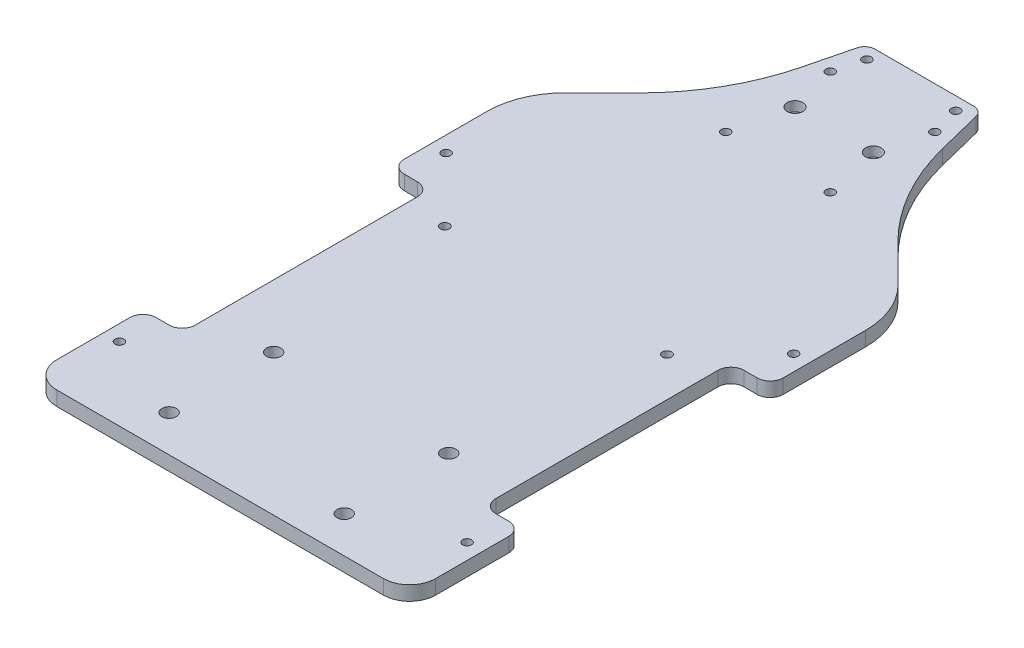
from build123d import *

# Parameters (mm, degrees)
DECK_BASE_DEPTH     = 5.5
BOLT_SLOT_REACH     = 7.5
SKETCH_3_R          = 1.7
FILLET_1_R          = 4
CUT_EXTRUDE_2_REACH = 7.5
SKETCH_11_W         = 15
SKETCH_11_H         = 95
CUT_EXTRUDE_1_REACH = 7.5
SKETCH_10_W         = 145
SKETCH_10_H         = 38.5
FILLET_2_R          = 10
FILLET_3_R          = 5
LIDAR_SLOT_REACH    = 7.5
SKETCH_4_R          = 1.7
VESC_SLOT_REACH     = 7.5
SKETCH_6_R          = 2.75
NANO_SLOT_REACH     = 7.5
SKETCH_7_R          = 1.75
CUT_EXTRUDE_3_REACH = 7.5
SKETCH_12_R         = 1.75
SKETCH_13_R         = 3
CUT_EXTRUDE_4_DEPTH = 3.7


with BuildPart() as part:
    # 스케치1 → Deck base (new body)
    with BuildSketch(Plane(origin=(0, 0, 0), x_dir=(1, 0, 0), z_dir=(0, 1, 0))):
        with BuildLine():
            Line((-72.5, 0), (-72.5, -180))
            ThreePointArc((-72.5, -180), (-69.571067812, -187.071067812), (-62.5, -190))
            Line((-62.5, -190), (-49.196112248, -190))
            ThreePointArc((-49.196112248, -190), (-47.589899161, -190.265015363), (-46.15395453, -191.031968194))
            Line((-46.15395453, -191.031968194), (-18.84604547, -211.968031806))
            ThreePointArc((-18.84604547, -211.968031806), (-17.410100839, -212.734984637), (-15.803887752, -213))
            Line((-15.803887752, -213), (15.803887752, -213))
            ThreePointArc((15.803887752, -213), (17.410100839, -212.734984637), (18.84604547, -211.968031806))
            Line((18.84604547, -211.968031806), (46.15395453, -191.031968194))
            ThreePointArc((46.15395453, -191.031968194), (47.589899161, -190.265015363), (49.196112248, -190))
            Line((49.196112248, -190), (62.5, -190))
            ThreePointArc((62.5, -190), (69.571067812, -187.071067812), (72.5, -180))
            Line((72.5, -180), (72.5, 0))
            ThreePointArc((72.5, 0), (70.204904333, 11.508182998), (63.670781605, 21.255540601))
            Line((63.670781605, 21.255540601), (49.478231298, 35.391496426))
            ThreePointArc((49.478231298, 35.391496426), (35.536990456, 53.662264501), (27, 75))
            Line((27, 75), (22, 95))
            Line((22, 95), (-22, 95))
            Line((-22, 95), (-27, 75))
            ThreePointArc((-27, 75), (-35.536990456, 53.662264501), (-49.478231298, 35.391496426))
            Line((-49.478231298, 35.391496426), (-63.670781605, 21.255540601))
            ThreePointArc((-63.670781605, 21.255540601), (-70.204904333, 11.508182998), (-72.5, 0))
        make_face()
    extrude(amount=DECK_BASE_DEPTH)

    # 스케치3 → Bolt slot (cut, up to next)
    with BuildSketch(Plane(origin=(0, 5.5, 0), x_dir=(1, 0, 0), z_dir=(0, 1, 0)), mode=Mode.PRIVATE) as bolt_slot_sk1:
        with Locations((17, 90)):
            Circle(SKETCH_3_R)
    bolt_slot_tool1 = extrude(bolt_slot_sk1.sketch, amount=-BOLT_SLOT_REACH, mode=Mode.PRIVATE) & part.part
    add(bolt_slot_tool1.solids().sort_by_distance((17, 5.5, -90))[0], mode=Mode.SUBTRACT)
    # 스케치3 → Bolt slot (cut, up to next)
    with BuildSketch(Plane(origin=(0, 5.5, 0), x_dir=(1, 0, 0), z_dir=(0, 1, 0)), mode=Mode.PRIVATE) as bolt_slot_sk2:
        with Locations((66.5, -146.5)):
            Circle(SKETCH_3_R)
    bolt_slot_tool2 = extrude(bolt_slot_sk2.sketch, amount=-BOLT_SLOT_REACH, mode=Mode.PRIVATE) & part.part
    add(bolt_slot_tool2.solids().sort_by_distance((66.5, 5.5, 146.5))[0], mode=Mode.SUBTRACT)
    # 스케치3 → Bolt slot (cut, up to next)
    with BuildSketch(Plane(origin=(0, 5.5, 0), x_dir=(1, 0, 0), z_dir=(0, 1, 0)), mode=Mode.PRIVATE) as bolt_slot_sk3:
        with Locations((66.5, -116.5)):
            Circle(SKETCH_3_R)
    bolt_slot_tool3 = extrude(bolt_slot_sk3.sketch, amount=-BOLT_SLOT_REACH, mode=Mode.PRIVATE) & part.part
    add(bolt_slot_tool3.solids().sort_by_distance((66.5, 5.5, 116.5))[0], mode=Mode.SUBTRACT)
    # 스케치3 → Bolt slot (cut, up to next)
    with BuildSketch(Plane(origin=(0, 5.5, 0), x_dir=(1, 0, 0), z_dir=(0, 1, 0)), mode=Mode.PRIVATE) as bolt_slot_sk4:
        with Locations((66.5, -51.5)):
            Circle(SKETCH_3_R)
    bolt_slot_tool4 = extrude(bolt_slot_sk4.sketch, amount=-BOLT_SLOT_REACH, mode=Mode.PRIVATE) & part.part
    add(bolt_slot_tool4.solids().sort_by_distance((66.5, 5.5, 51.5))[0], mode=Mode.SUBTRACT)
    # 스케치3 → Bolt slot (cut, up to next)
    with BuildSketch(Plane(origin=(0, 5.5, 0), x_dir=(1, 0, 0), z_dir=(0, 1, 0)), mode=Mode.PRIVATE) as bolt_slot_sk5:
        with Locations((66.5, -21.5)):
            Circle(SKETCH_3_R)
    bolt_slot_tool5 = extrude(bolt_slot_sk5.sketch, amount=-BOLT_SLOT_REACH, mode=Mode.PRIVATE) & part.part
    add(bolt_slot_tool5.solids().sort_by_distance((66.5, 5.5, 21.5))[0], mode=Mode.SUBTRACT)
    # 스케치3 → Bolt slot (cut, up to next)
    with BuildSketch(Plane(origin=(0, 5.5, 0), x_dir=(1, 0, 0), z_dir=(0, 1, 0)), mode=Mode.PRIVATE) as bolt_slot_sk6:
        with Locations((-66.5, -21.5)):
            Circle(SKETCH_3_R)
    bolt_slot_tool6 = extrude(bolt_slot_sk6.sketch, amount=-BOLT_SLOT_REACH, mode=Mode.PRIVATE) & part.part
    add(bolt_slot_tool6.solids().sort_by_distance((-66.5, 5.5, 21.5))[0], mode=Mode.SUBTRACT)
    # 스케치3 → Bolt slot (cut, up to next)
    with BuildSketch(Plane(origin=(0, 5.5, 0), x_dir=(1, 0, 0), z_dir=(0, 1, 0)), mode=Mode.PRIVATE) as bolt_slot_sk7:
        with Locations((-66.5, -51.5)):
            Circle(SKETCH_3_R)
    bolt_slot_tool7 = extrude(bolt_slot_sk7.sketch, amount=-BOLT_SLOT_REACH, mode=Mode.PRIVATE) & part.part
    add(bolt_slot_tool7.solids().sort_by_distance((-66.5, 5.5, 51.5))[0], mode=Mode.SUBTRACT)
    # 스케치3 → Bolt slot (cut, up to next)
    with BuildSketch(Plane(origin=(0, 5.5, 0), x_dir=(1, 0, 0), z_dir=(0, 1, 0)), mode=Mode.PRIVATE) as bolt_slot_sk8:
        with Locations((-66.5, -116.5)):
            Circle(SKETCH_3_R)
    bolt_slot_tool8 = extrude(bolt_slot_sk8.sketch, amount=-BOLT_SLOT_REACH, mode=Mode.PRIVATE) & part.part
    add(bolt_slot_tool8.solids().sort_by_distance((-66.5, 5.5, 116.5))[0], mode=Mode.SUBTRACT)
    # 스케치3 → Bolt slot (cut, up to next)
    with BuildSketch(Plane(origin=(0, 5.5, 0), x_dir=(1, 0, 0), z_dir=(0, 1, 0)), mode=Mode.PRIVATE) as bolt_slot_sk9:
        with Locations((-66.5, -146.5)):
            Circle(SKETCH_3_R)
    bolt_slot_tool9 = extrude(bolt_slot_sk9.sketch, amount=-BOLT_SLOT_REACH, mode=Mode.PRIVATE) & part.part
    add(bolt_slot_tool9.solids().sort_by_distance((-66.5, 5.5, 146.5))[0], mode=Mode.SUBTRACT)
    # 스케치3 → Bolt slot (cut, up to next)
    with BuildSketch(Plane(origin=(0, 5.5, 0), x_dir=(1, 0, 0), z_dir=(0, 1, 0)), mode=Mode.PRIVATE) as bolt_slot_sk10:
        with Locations((-17, 90)):
            Circle(SKETCH_3_R)
    bolt_slot_tool10 = extrude(bolt_slot_sk10.sketch, amount=-BOLT_SLOT_REACH, mode=Mode.PRIVATE) & part.part
    add(bolt_slot_tool10.solids().sort_by_distance((-17, 5.5, -90))[0], mode=Mode.SUBTRACT)

    # 필렛1
    fillet_1_edges = [part.edges().sort_by_distance(p)[0] for p in [
        (22, 2.75, -95),
        (-22, 2.75, -95),
    ]]
    fillet(fillet_1_edges, radius=FILLET_1_R)

    # 스케치11 → 컷-돌출2 (cut, up to next)
    with BuildSketch(Plane(origin=(0, 5.5, 0), x_dir=(1, 0, 0), z_dir=(0, 1, 0)), mode=Mode.PRIVATE) as cut_extrude_2_sk1:
        with Locations((-65, -84)):
            Rectangle(SKETCH_11_W, SKETCH_11_H)
    cut_extrude_2_tool1 = extrude(cut_extrude_2_sk1.sketch, amount=-CUT_EXTRUDE_2_REACH, mode=Mode.PRIVATE) & part.part
    add(cut_extrude_2_tool1.solids().sort_by_distance((-65, 5.5, 84))[0], mode=Mode.SUBTRACT)
    # 스케치11 → 컷-돌출2 (cut, up to next)
    with BuildSketch(Plane(origin=(0, 5.5, 0), x_dir=(1, 0, 0), z_dir=(0, 1, 0)), mode=Mode.PRIVATE) as cut_extrude_2_sk2:
        with Locations((65, -84)):
            Rectangle(SKETCH_11_W, SKETCH_11_H)
    cut_extrude_2_tool2 = extrude(cut_extrude_2_sk2.sketch, amount=-CUT_EXTRUDE_2_REACH, mode=Mode.PRIVATE) & part.part
    add(cut_extrude_2_tool2.solids().sort_by_distance((65, 5.5, 84))[0], mode=Mode.SUBTRACT)

    # 스케치10 → 컷-돌출1 (cut, up to next)
    with BuildSketch(Plane(origin=(0, 5.5, 0), x_dir=(1, 0, 0), z_dir=(0, 1, 0)), mode=Mode.PRIVATE) as cut_extrude_1_sk1:
        with Locations((0, -193.75)):
            Rectangle(SKETCH_10_W, SKETCH_10_H)
    cut_extrude_1_tool1 = extrude(cut_extrude_1_sk1.sketch, amount=-CUT_EXTRUDE_1_REACH, mode=Mode.PRIVATE) & part.part
    add(cut_extrude_1_tool1.solids().sort_by_distance((0, 5.5, 193.75))[0], mode=Mode.SUBTRACT)

    # 필렛2
    fillet_2_edges = [part.edges().sort_by_distance(p)[0] for p in [
        (72.5, 2.75, 174.5),
        (-72.5, 2.75, 174.5),
    ]]
    fillet(fillet_2_edges, radius=FILLET_2_R)

    # 필렛3
    fillet_3_edges = [part.edges().sort_by_distance(p)[0] for p in [
        (-72.5, 2.75, 131.5),
        (-72.5, 2.75, 36.5),
        (-57.5, 2.75, 36.5),
        (-57.5, 2.75, 131.5),
        (72.5, 2.75, 36.5),
        (72.5, 2.75, 131.5),
        (57.5, 2.75, 131.5),
        (57.5, 2.75, 36.5),
    ]]
    fillet(fillet_3_edges, radius=FILLET_3_R)

    # 스케치4 → Lidar slot (cut, up to next)
    with BuildSketch(Plane(origin=(0, 5.5, 0), x_dir=(1, 0, 0), z_dir=(0, 1, 0)), mode=Mode.PRIVATE) as lidar_slot_sk1:
        with Locations((-20, 79)):
            Circle(SKETCH_4_R)
    lidar_slot_tool1 = extrude(lidar_slot_sk1.sketch, amount=-LIDAR_SLOT_REACH, mode=Mode.PRIVATE) & part.part
    add(lidar_slot_tool1.solids().sort_by_distance((-20, 5.5, -79))[0], mode=Mode.SUBTRACT)
    # 스케치4 → Lidar slot (cut, up to next)
    with BuildSketch(Plane(origin=(0, 5.5, 0), x_dir=(1, 0, 0), z_dir=(0, 1, 0)), mode=Mode.PRIVATE) as lidar_slot_sk2:
        with Locations((-20, 39)):
            Circle(SKETCH_4_R)
    lidar_slot_tool2 = extrude(lidar_slot_sk2.sketch, amount=-LIDAR_SLOT_REACH, mode=Mode.PRIVATE) & part.part
    add(lidar_slot_tool2.solids().sort_by_distance((-20, 5.5, -39))[0], mode=Mode.SUBTRACT)
    # 스케치4 → Lidar slot (cut, up to next)
    with BuildSketch(Plane(origin=(0, 5.5, 0), x_dir=(1, 0, 0), z_dir=(0, 1, 0)), mode=Mode.PRIVATE) as lidar_slot_sk3:
        with Locations((20, 39)):
            Circle(SKETCH_4_R)
    lidar_slot_tool3 = extrude(lidar_slot_sk3.sketch, amount=-LIDAR_SLOT_REACH, mode=Mode.PRIVATE) & part.part
    add(lidar_slot_tool3.solids().sort_by_distance((20, 5.5, -39))[0], mode=Mode.SUBTRACT)
    # 스케치4 → Lidar slot (cut, up to next)
    with BuildSketch(Plane(origin=(0, 5.5, 0), x_dir=(1, 0, 0), z_dir=(0, 1, 0)), mode=Mode.PRIVATE) as lidar_slot_sk4:
        with Locations((20, 79)):
            Circle(SKETCH_4_R)
    lidar_slot_tool4 = extrude(lidar_slot_sk4.sketch, amount=-LIDAR_SLOT_REACH, mode=Mode.PRIVATE) & part.part
    add(lidar_slot_tool4.solids().sort_by_distance((20, 5.5, -79))[0], mode=Mode.SUBTRACT)

    # 스케치6 → Vesc slot (cut, up to next)
    with BuildSketch(Plane(origin=(0, 5.5, 0), x_dir=(1, 0, 0), z_dir=(0, 1, 0)), mode=Mode.PRIVATE) as vesc_slot_sk1:
        with Locations((33.5, -120.5)):
            Circle(SKETCH_6_R)
    vesc_slot_tool1 = extrude(vesc_slot_sk1.sketch, amount=-VESC_SLOT_REACH, mode=Mode.PRIVATE) & part.part
    add(vesc_slot_tool1.solids().sort_by_distance((33.5, 5.5, 120.5))[0], mode=Mode.SUBTRACT)
    # 스케치6 → Vesc slot (cut, up to next)
    with BuildSketch(Plane(origin=(0, 5.5, 0), x_dir=(1, 0, 0), z_dir=(0, 1, 0)), mode=Mode.PRIVATE) as vesc_slot_sk2:
        with Locations((33.5, -160.5)):
            Circle(SKETCH_6_R)
    vesc_slot_tool2 = extrude(vesc_slot_sk2.sketch, amount=-VESC_SLOT_REACH, mode=Mode.PRIVATE) & part.part
    add(vesc_slot_tool2.solids().sort_by_distance((33.5, 5.5, 160.5))[0], mode=Mode.SUBTRACT)
    # 스케치6 → Vesc slot (cut, up to next)
    with BuildSketch(Plane(origin=(0, 5.5, 0), x_dir=(1, 0, 0), z_dir=(0, 1, 0)), mode=Mode.PRIVATE) as vesc_slot_sk3:
        with Locations((-33.5, -160.5)):
            Circle(SKETCH_6_R)
    vesc_slot_tool3 = extrude(vesc_slot_sk3.sketch, amount=-VESC_SLOT_REACH, mode=Mode.PRIVATE) & part.part
    add(vesc_slot_tool3.solids().sort_by_distance((-33.5, 5.5, 160.5))[0], mode=Mode.SUBTRACT)
    # 스케치6 → Vesc slot (cut, up to next)
    with BuildSketch(Plane(origin=(0, 5.5, 0), x_dir=(1, 0, 0), z_dir=(0, 1, 0)), mode=Mode.PRIVATE) as vesc_slot_sk4:
        with Locations((-33.5, -120.5)):
            Circle(SKETCH_6_R)
    vesc_slot_tool4 = extrude(vesc_slot_sk4.sketch, amount=-VESC_SLOT_REACH, mode=Mode.PRIVATE) & part.part
    add(vesc_slot_tool4.solids().sort_by_distance((-33.5, 5.5, 120.5))[0], mode=Mode.SUBTRACT)

    # 스케치7 → Nano slot (cut, up to next)
    with BuildSketch(Plane(origin=(0, 5.5, 0), x_dir=(1, 0, 0), z_dir=(0, 1, 0)), mode=Mode.PRIVATE) as nano_slot_sk1:
        with Locations((-42.5, -46)):
            Circle(SKETCH_7_R)
    nano_slot_tool1 = extrude(nano_slot_sk1.sketch, amount=-NANO_SLOT_REACH, mode=Mode.PRIVATE) & part.part
    add(nano_slot_tool1.solids().sort_by_distance((-42.5, 5.5, 46))[0], mode=Mode.SUBTRACT)
    # 스케치7 → Nano slot (cut, up to next)
    with BuildSketch(Plane(origin=(0, 5.5, 0), x_dir=(1, 0, 0), z_dir=(0, 1, 0)), mode=Mode.PRIVATE) as nano_slot_sk2:
        with Locations((42.5, -46)):
            Circle(SKETCH_7_R)
    nano_slot_tool2 = extrude(nano_slot_sk2.sketch, amount=-NANO_SLOT_REACH, mode=Mode.PRIVATE) & part.part
    add(nano_slot_tool2.solids().sort_by_distance((42.5, 5.5, 46))[0], mode=Mode.SUBTRACT)

    # 스케치12 → 컷-돌출3 (cut, up to next)
    with BuildSketch(Plane(origin=(0, 5.5, 0), x_dir=(1, 0, 0), z_dir=(0, 1, 0)), mode=Mode.PRIVATE) as cut_extrude_3_sk1:
        with Locations((-15, 60.5)):
            Circle(SKETCH_12_R)
    cut_extrude_3_tool1 = extrude(cut_extrude_3_sk1.sketch, amount=-CUT_EXTRUDE_3_REACH, mode=Mode.PRIVATE) & part.part
    add(cut_extrude_3_tool1.solids().sort_by_distance((-15, 5.5, -60.5))[0], mode=Mode.SUBTRACT)
    # 스케치12 → 컷-돌출3 (cut, up to next)
    with BuildSketch(Plane(origin=(0, 5.5, 0), x_dir=(1, 0, 0), z_dir=(0, 1, 0)), mode=Mode.PRIVATE) as cut_extrude_3_sk2:
        with Locations((15, 60.5)):
            Circle(SKETCH_12_R)
    cut_extrude_3_tool2 = extrude(cut_extrude_3_sk2.sketch, amount=-CUT_EXTRUDE_3_REACH, mode=Mode.PRIVATE) & part.part
    add(cut_extrude_3_tool2.solids().sort_by_distance((15, 5.5, -60.5))[0], mode=Mode.SUBTRACT)

    # 스케치13 → 컷-돌출4 (cut)
    with BuildSketch(Plane(origin=(0, 5.5, 0), x_dir=(1, 0, 0), z_dir=(0, 1, 0))):
        with Locations((-15, 60.5)):
            Circle(SKETCH_13_R)
        with Locations((15, 60.5)):
            Circle(SKETCH_13_R)
    extrude(amount=-CUT_EXTRUDE_4_DEPTH, mode=Mode.SUBTRACT)


solid = part.part
